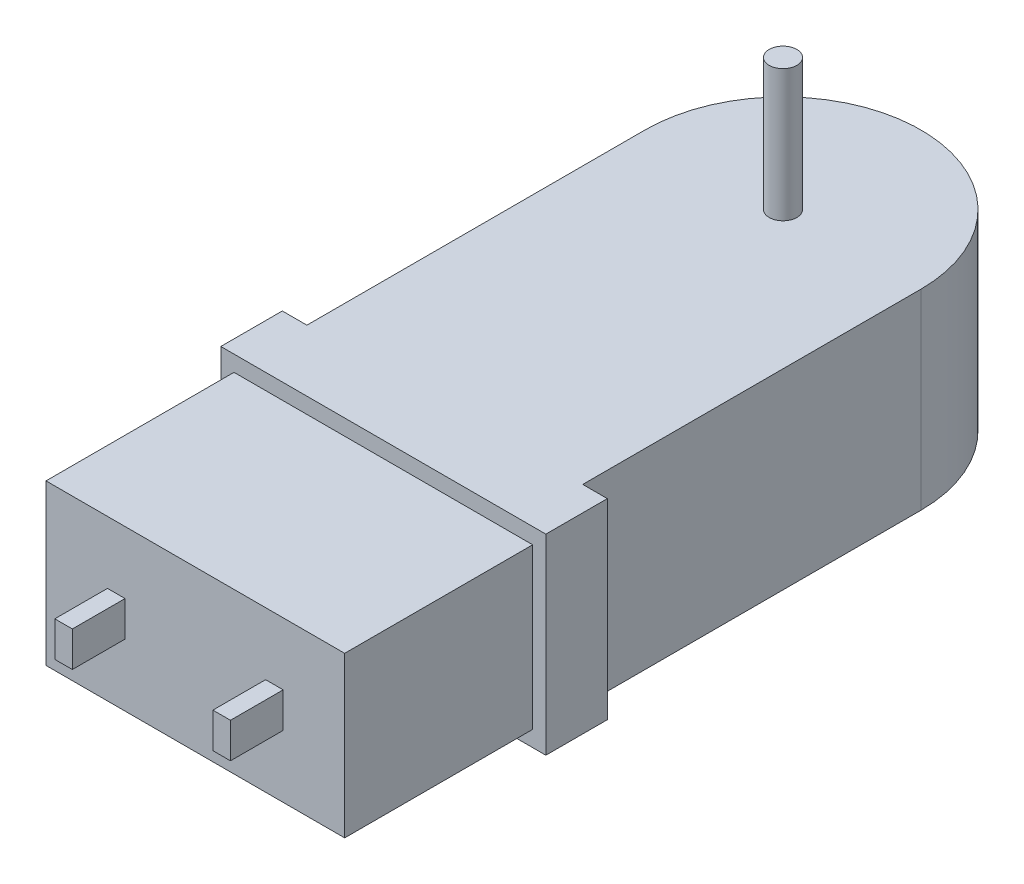
from build123d import *

# Parameters (mm, degrees)
EXTRUDE1_DEPTH     = 6.9215
SKETCH2_W          = 23.495
SKETCH2_H          = 1.143
CUT_EXTRUDE1_DEPTH = 13.589
SKETCH3_R          = 1
EXTRUDE2_DEPTH     = 9.525
SKETCH4_W          = 1.27
SKETCH4_H          = 2.54
EXTRUDE3_DEPTH     = 3.81
EXTRUDE3_2_DEPTH   = 3.81


with BuildPart() as part:
    # Sketch1 → Extrude1 (new body, symmetric)
    with BuildSketch(Plane(origin=(0, 0, 0), x_dir=(1, 0, 0), z_dir=(0, 1, 0))):
        with BuildLine():
            Line((-9.9695, -24.4475), (-11.7475, -24.4475))
            Line((-11.7475, -24.4475), (-11.7475, -28.8925))
            Line((-11.7475, -28.8925), (-10.795, -28.8925))
            Line((-10.795, -28.8925), (-10.795, -42.4815))
            Line((-10.795, -42.4815), (10.795, -42.4815))
            Line((10.795, -42.4815), (10.795, -28.8925))
            Line((10.795, -28.8925), (11.7475, -28.8925))
            Line((11.7475, -28.8925), (11.7475, -24.4475))
            Line((11.7475, -24.4475), (9.9695, -24.4475))
            Line((9.9695, -24.4475), (9.9695, 0))
            ThreePointArc((9.9695, 0), (0, 9.9695), (-9.9695, 0))
            Line((-9.9695, 0), (-9.9695, -24.4475))
        make_face()
    extrude(amount=EXTRUDE1_DEPTH, both=True)

    # Sketch2 → Cut-Extrude1 (cut)
    with BuildSketch(Plane.XY.offset(42.4815)):
        with Locations((0, 6.35)):
            Rectangle(SKETCH2_W, SKETCH2_H)
        with Locations((0, -6.35)):
            Rectangle(SKETCH2_W, SKETCH2_H)
    extrude(amount=-CUT_EXTRUDE1_DEPTH, mode=Mode.SUBTRACT)


with BuildPart() as body_2:
    # Sketch3 → Extrude2 (new body)
    with BuildSketch(Plane(origin=(0, 6.9215, 0), x_dir=(1, 0, 0), z_dir=(0, 1, 0))):
        with Locations(Location((0, 0, 0), (0, 0, 270))):  # turned: the seam where the file's is
            Circle(SKETCH3_R)
    extrude(amount=EXTRUDE2_DEPTH)


with BuildPart() as body_3:
    # Sketch4 → Extrude3 (new body)
    with BuildSketch(Plane.XY.offset(42.4815)):
        with Locations((-5.715, 0)):
            Rectangle(SKETCH4_W, SKETCH4_H)
    extrude(amount=EXTRUDE3_DEPTH)


with BuildPart() as body_4:
    # Sketch4 → Extrude3 2 (new body)
    with BuildSketch(Plane.XY.offset(42.4815)):
        with Locations((5.715, 0)):
            Rectangle(SKETCH4_W, SKETCH4_H)
    extrude(amount=EXTRUDE3_2_DEPTH)


solid = Compound([part.part, body_2.part, body_3.part, body_4.part])
